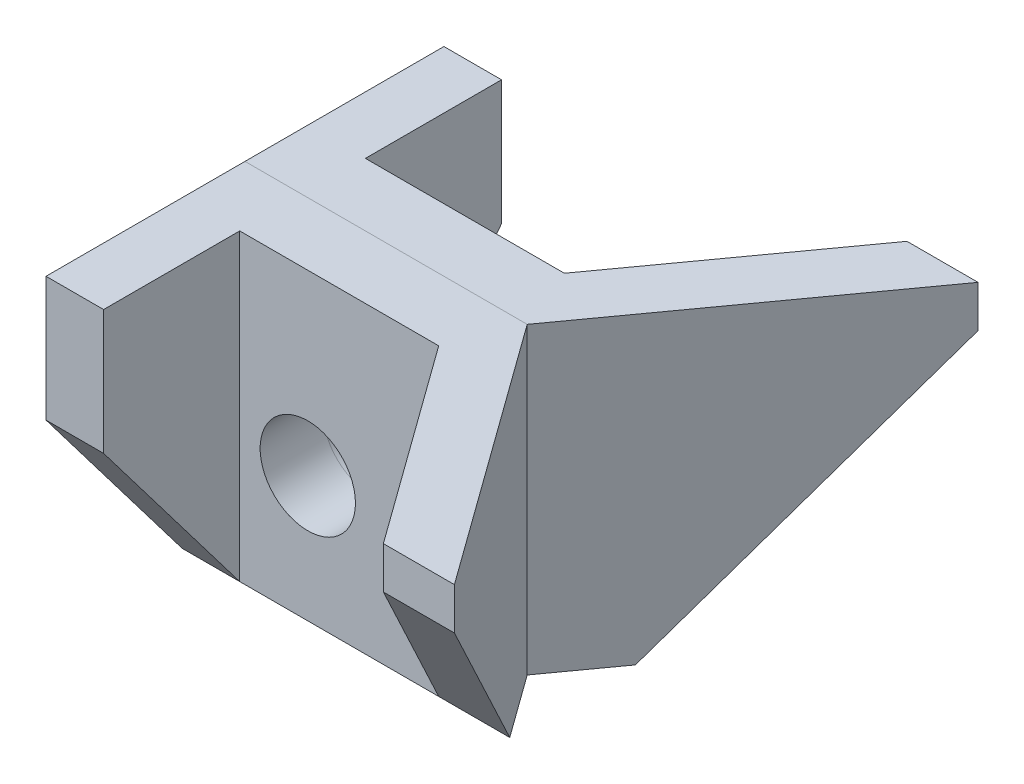
from build123d import *

# Parameters (mm, degrees)
SKETCH1_R                      = 4.55
BOSS_EXTRUDE1_DEPTH            = 25
SKETCH2_W                      = 5.5
SKETCH2_H                      = 6
CUT_EXTRUDE1_DEPTH             = 30
CUT_EXTRUDE3_REACH             = 7.5
CUT_EXTRUDE3_DIRECTION_2_REACH = 41.5


with BuildPart() as part:
    # Sketch1 → Boss-Extrude1 (new body)
    with BuildSketch(Plane.XY):
        Polygon((-12, -12), (-12, 17), (33, 17), (33, 12), (33, -12), (0, -12), align=None)
        Circle(SKETCH1_R, mode=Mode.SUBTRACT)
    extrude(amount=-BOSS_EXTRUDE1_DEPTH)

    # Sketch2 → Cut-Extrude1 (cut, through all)
    with BuildSketch(Plane(origin=(0, 17, 0), x_dir=(1, 0, 0), z_dir=(0, 1, 0))):
        Polygon((33, 0), (33, 25), (14.951933913, 0), align=None)
        Polygon((26.216530226, 25), (-6.5, 25), (-6.5, 19), (-6.5, 6), (12.5, 6), align=None)
        with Locations((-9.25, 22)):
            Rectangle(SKETCH2_W, SKETCH2_H)
    extrude(amount=-CUT_EXTRUDE1_DEPTH, mode=Mode.SUBTRACT)

    # Cut-Extrude3: up to this face of the body (flat: up to its plane)
    cut_extrude3_end = Plane(part.part.faces().sort_by_distance((-12, 2.5, -9.5))[0])
    # Sketch4 → Cut-Extrude3 (cut, up to the picked face)
    with BuildSketch(Plane(origin=(-6.5, 0, 0), x_dir=(0, 0, -1), z_dir=(1, 0, 0)), mode=Mode.PRIVATE) as cut_extrude3_sk1:
        Polygon((25, 13), (19, 5.105263158), (19, -12), (25, -12), align=None)
    cut_extrude3_tool1 = split(extrude(cut_extrude3_sk1.sketch, amount=-CUT_EXTRUDE3_REACH, mode=Mode.PRIVATE), bisect_by=cut_extrude3_end, keep=Keep.BOTH, mode=Mode.PRIVATE)
    add(cut_extrude3_tool1.solids().sort_by_distance((-6.5, -1.350329, -22.1875))[0], mode=Mode.SUBTRACT)
    # Sketch4 → Cut-Extrude3 (cut, up to the picked face)
    with BuildSketch(Plane(origin=(-6.5, 0, 0), x_dir=(0, 0, -1), z_dir=(1, 0, 0)), mode=Mode.PRIVATE) as cut_extrude3_sk2:
        Polygon((19, 5.105263158), (6, -12), (19, -12), align=None)
    cut_extrude3_tool2 = split(extrude(cut_extrude3_sk2.sketch, amount=-CUT_EXTRUDE3_REACH, mode=Mode.PRIVATE), bisect_by=cut_extrude3_end, keep=Keep.BOTH, mode=Mode.PRIVATE)
    add(cut_extrude3_tool2.solids().sort_by_distance((-6.5, -6.298246, -14.666667))[0], mode=Mode.SUBTRACT)

    # Cut-Extrude3 direction 2: up to this face of the body (flat: up to its plane)
    cut_extrude3_direction_2_end = Plane(part.part.faces().sort_by_distance((23.975966956, 2.5, -12.5))[0])
    # Sketch4 → Cut-Extrude3 direction 2 (cut, up to the picked face)
    with BuildSketch(Plane(origin=(-6.5, 0, 0), x_dir=(0, 0, -1), z_dir=(1, 0, 0)), mode=Mode.PRIVATE) as cut_extrude3_direction_2_sk1:
        Polygon((25, 13), (19, 5.105263158), (19, -12), (25, -12), align=None)
    cut_extrude3_direction_2_tool1 = split(extrude(cut_extrude3_direction_2_sk1.sketch, amount=CUT_EXTRUDE3_DIRECTION_2_REACH, mode=Mode.PRIVATE), bisect_by=cut_extrude3_direction_2_end, keep=Keep.BOTH, mode=Mode.PRIVATE)
    add(cut_extrude3_direction_2_tool1.solids().sort_by_distance((-6.5, -1.350329, -22.1875))[0], mode=Mode.SUBTRACT)
    # Sketch4 → Cut-Extrude3 direction 2 (cut, up to the picked face)
    with BuildSketch(Plane(origin=(-6.5, 0, 0), x_dir=(0, 0, -1), z_dir=(1, 0, 0)), mode=Mode.PRIVATE) as cut_extrude3_direction_2_sk2:
        Polygon((19, 5.105263158), (6, -12), (19, -12), align=None)
    cut_extrude3_direction_2_tool2 = split(extrude(cut_extrude3_direction_2_sk2.sketch, amount=CUT_EXTRUDE3_DIRECTION_2_REACH, mode=Mode.PRIVATE), bisect_by=cut_extrude3_direction_2_end, keep=Keep.BOTH, mode=Mode.PRIVATE)
    add(cut_extrude3_direction_2_tool2.solids().sort_by_distance((-6.5, -6.298246, -14.666667))[0], mode=Mode.SUBTRACT)


with BuildPart() as body_2:
    # Mirror3: mirrored copy
    add(part.part.mirror(Plane.XY))


solid = Compound([part.part, body_2.part])
